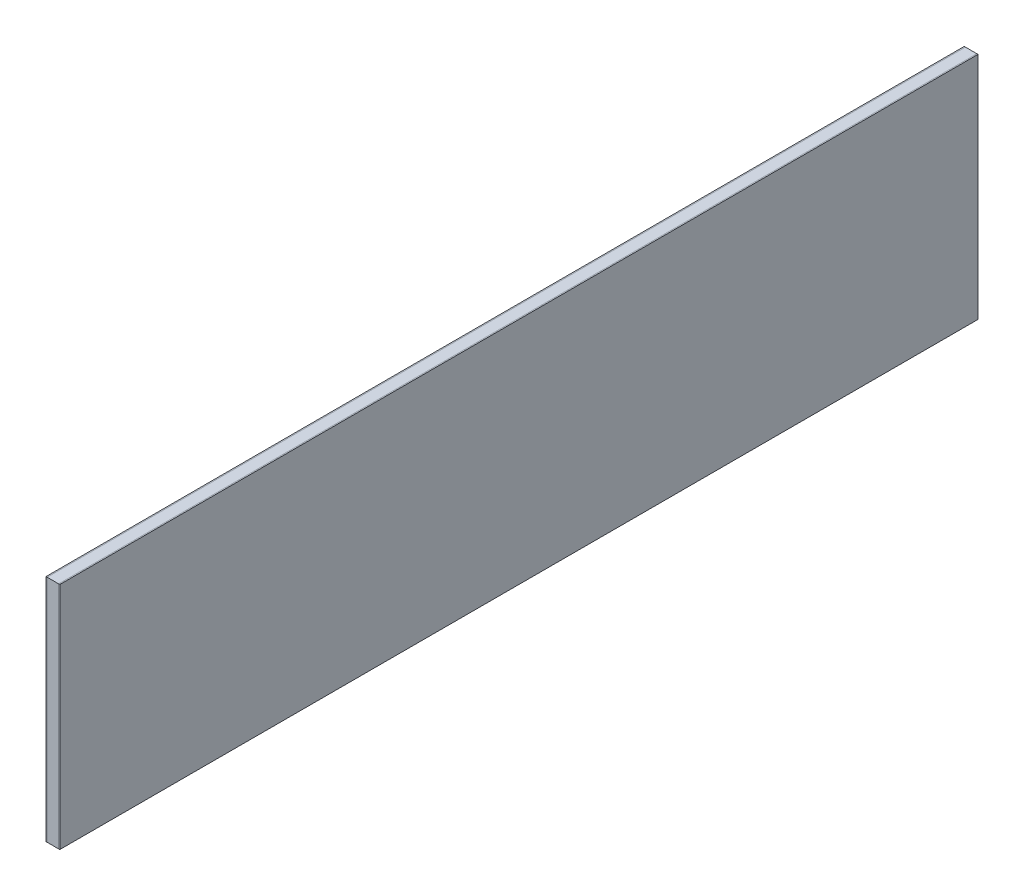
from build123d import *

# Parameters (mm, degrees)
SKETCH1_W           = 200
SKETCH1_H           = 50
BOSS_EXTRUDE1_DEPTH = 0.25
SKETCH2_W           = 200
SKETCH2_H           = 50
BOSS_EXTRUDE2_DEPTH = 2.5
SKETCH3_W           = 200
SKETCH3_H           = 50
BOSS_EXTRUDE3_DEPTH = 0.25


with BuildPart() as part:
    # Sketch1 → Boss-Extrude1 (new body)
    with BuildSketch(Plane(origin=(0, 0, 0), x_dir=(0, 0, -1), z_dir=(1, 0, 0))):
        Rectangle(SKETCH1_W, SKETCH1_H)
    extrude(amount=BOSS_EXTRUDE1_DEPTH)


with BuildPart() as body_2:
    # Sketch2 → Boss-Extrude2 (new body)
    with BuildSketch(Plane.ZY):
        Rectangle(SKETCH2_W, SKETCH2_H)
    extrude(amount=BOSS_EXTRUDE2_DEPTH)


with BuildPart() as body_3:
    # Sketch3 → Boss-Extrude3 (new body)
    with BuildSketch(Plane.ZY.offset(2.5)):
        Rectangle(SKETCH3_W, SKETCH3_H)
    extrude(amount=BOSS_EXTRUDE3_DEPTH)


solid = Compound([part.part, body_2.part, body_3.part])
